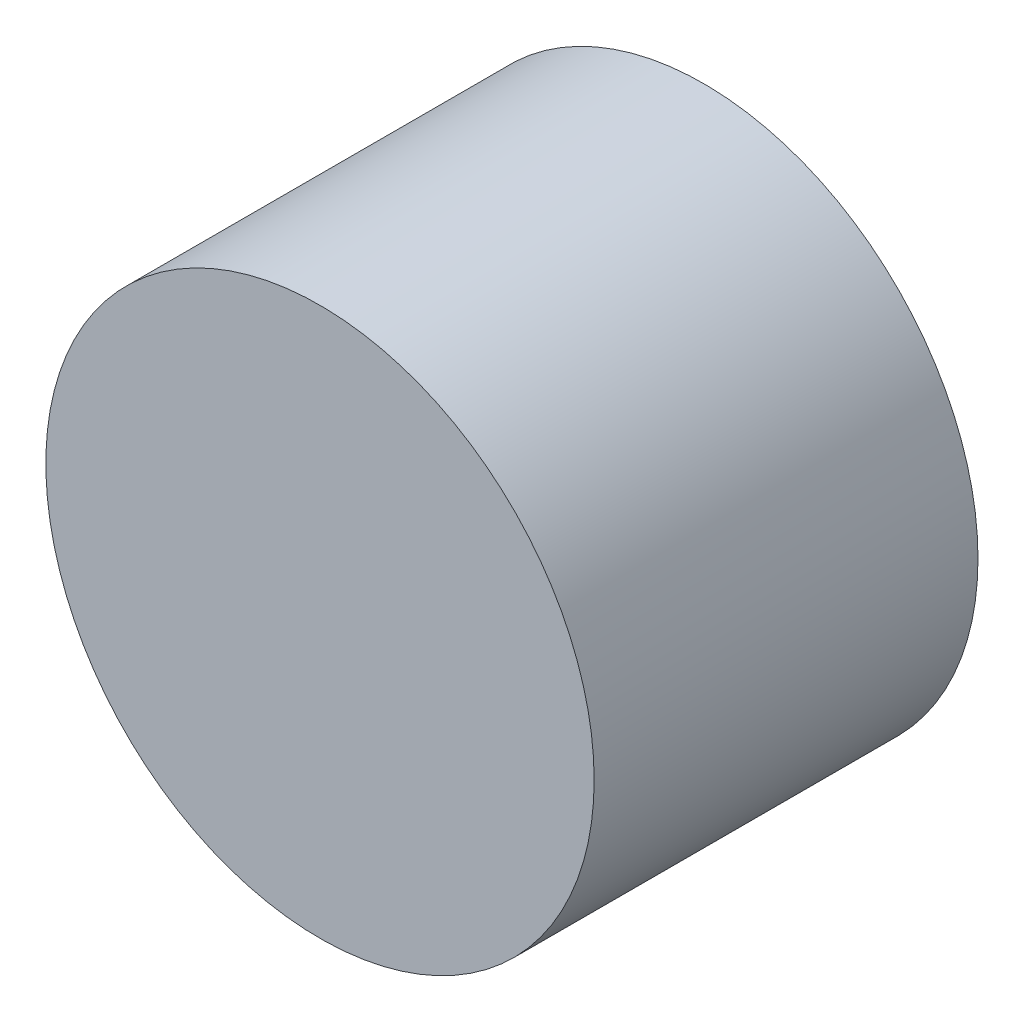
from build123d import *

# Parameters (mm, degrees)
SKETCH1_R           = 6.35
BOSS_EXTRUDE1_DEPTH = 8.89


with BuildPart() as part:
    # Sketch1 → Boss-Extrude1 (new body)
    with BuildSketch(Plane.XY):
        Circle(SKETCH1_R)
    extrude(amount=BOSS_EXTRUDE1_DEPTH)


solid = part.part
